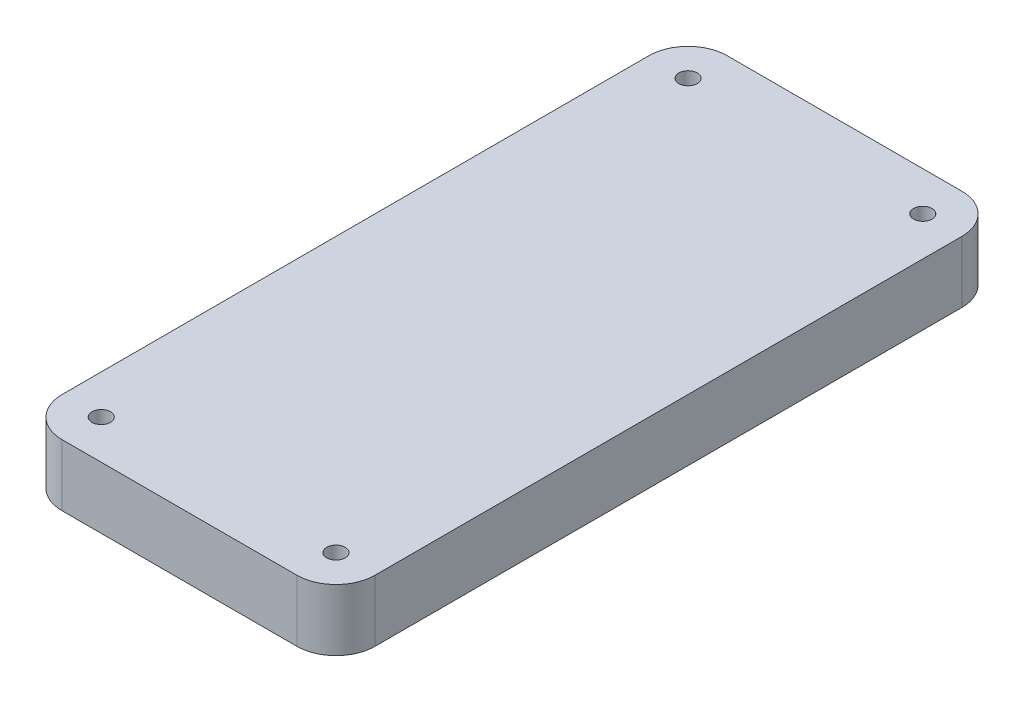
from build123d import *

# Parameters (mm, degrees)
SKETCH1_W           = 101.6
SKETCH1_H           = 215.9
BOSS_EXTRUDE2_DEPTH = 20
FILLET1_R           = 12.7
SKETCH5_R           = 3
CUT_EXTRUDE1_DEPTH  = 21


with BuildPart() as part:
    # Sketch1 → Boss-Extrude2 (new body)
    with BuildSketch(Plane(origin=(0, 0, 0), x_dir=(1, 0, 0), z_dir=(0, 1, 0))):
        with Locations((50.8, 107.95)):
            Rectangle(SKETCH1_W, SKETCH1_H)
    extrude(amount=BOSS_EXTRUDE2_DEPTH)

    # Fillet1
    fillet1_edges = [part.edges().sort_by_distance(p)[0] for p in [
        (0, 10, -215.9),
        (101.6, 10, -215.9),
        (101.6, 10, 0),
        (0, 10, 0),
    ]]
    fillet(fillet1_edges, radius=FILLET1_R)

    # Sketch5 → Cut-Extrude1 (cut, through all)
    with BuildSketch(Plane(origin=(0, 0, 0), x_dir=(-1, 0, 0), z_dir=(0, -1, 0))):
        with Locations((-88.9, 203.2)):
            Circle(SKETCH5_R)
        with Locations((-12.7, 203.2)):
            Circle(SKETCH5_R)
        with Locations((-88.9, 12.7)):
            Circle(SKETCH5_R)
        with Locations((-12.7, 12.7)):
            Circle(SKETCH5_R)
    extrude(amount=-CUT_EXTRUDE1_DEPTH, mode=Mode.SUBTRACT)


solid = part.part
